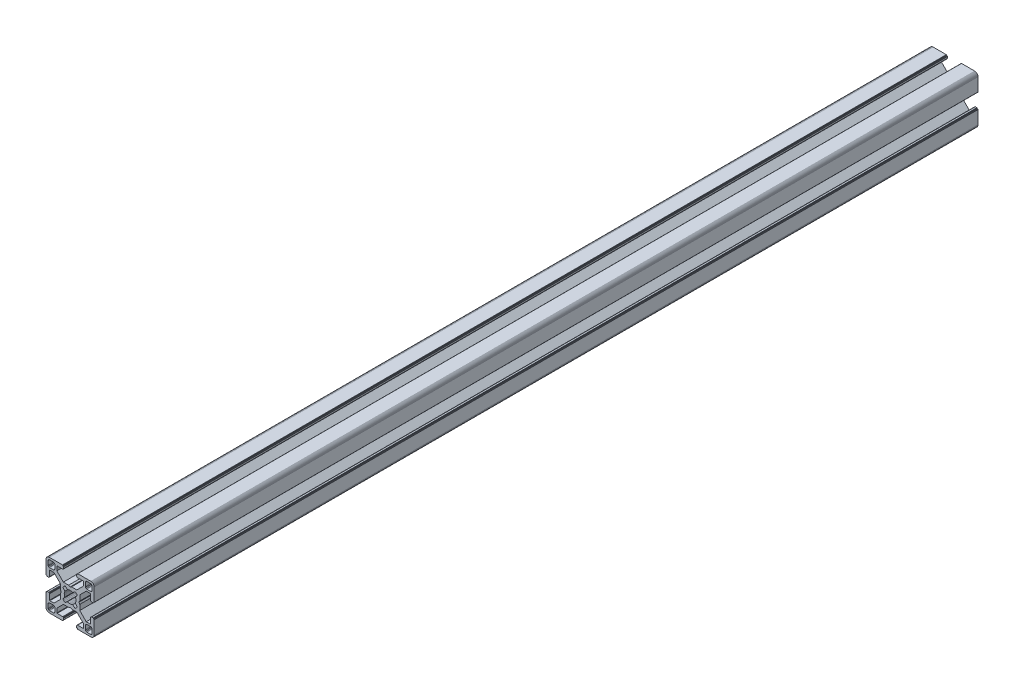
from build123d import *

# Parameters (mm, degrees)
BOSS_EXTRUDE1_DEPTH = 550


with BuildPart() as part:
    # Sketch1 → Boss-Extrude1 (new body)
    with BuildSketch(Plane.XY):
        Polygon((28.34729664, 29.969613999), (28.000000864, 29.999999329), (19.750000909, 29.999999329), (19.715268165, 29.996961355), (19.681595266, 29.987938702), (19.649999216, 29.973205179), (19.621443003, 29.953207821), (19.596790895, 29.928557575), (19.576793537, 29.899999499), (19.562061876, 29.868405312), (19.55303736, 29.834728688), (19.549999386, 29.799999669), (19.549999386, 29.699999839), (19.546961412, 29.665268958), (19.537936896, 29.631596059), (19.523203373, 29.599998146), (19.503207877, 29.571441934), (19.478557631, 29.546789825), (19.449999556, 29.526794329), (19.418403506, 29.512060806), (19.384728745, 29.503038153), (19.349999726, 29.500000179), (19.249999896, 29.500000179), (19.215267517, 29.496958527), (19.181592755, 29.487935874), (19.149996706, 29.47320235), (19.12143863, 29.453206855), (19.096788384, 29.428554746), (19.076791026, 29.399996671), (19.062057503, 29.368402484), (19.05303485, 29.334725859), (19.049996876, 29.299998703), (19.049996876, 28.39999837), (19.059110798, 28.29580945), (19.08618062, 28.194785165), (19.13038119, 28.099997016), (19.190369539, 28.014324653), (19.264324002, 27.94037019), (19.349996366, 27.88038184), (19.444784515, 27.836181271), (19.545806937, 27.809111449), (19.650010894, 27.799984574), (23.050010706, 27.799984574), (23.084741588, 27.7969466), (23.118414487, 27.787923946), (23.150012399, 27.773190423), (23.178568612, 27.753193065), (23.203220721, 27.728542819), (23.223218079, 27.699984744), (23.237949739, 27.668386831), (23.246974255, 27.634713932), (23.25001142, 27.59998608), (23.25001142, 25.049987618), (19.204474482, 20.999982084), (15.900007876, 20.999982084), (15.000008474, 20.48483404), (14.10000814, 20.999982084), (10.795543398, 20.999982084), (7.997342887, 23.801274731), (6.750011387, 25.049984589), (6.750011387, 27.599983051), (6.753049362, 27.634713932), (6.762072946, 27.668386831), (6.776805538, 27.699984744), (6.796801965, 27.728542819), (6.821454073, 27.753193065), (6.850011218, 27.773190423), (6.881607267, 27.787923946), (6.915282029, 27.7969466), (6.950011048, 27.799984574), (10.350011791, 27.799984574), (10.45420071, 27.809098497), (10.555223133, 27.836168318), (10.650011282, 27.880368888), (10.735683645, 27.940357238), (10.809638108, 28.014311701), (10.869626458, 28.099984064), (10.913827027, 28.194772213), (10.940895918, 28.295796498), (10.950010772, 28.399985417), (10.950010772, 29.299985751), (10.946974575, 29.334739239), (10.93795065, 29.368415522), (10.923215933, 29.400009153), (10.903218427, 29.428566473), (10.878566319, 29.45321765), (10.849999264, 29.473204166), (10.818403214, 29.487937689), (10.784728453, 29.496960342), (10.749999434, 29.500000179), (10.649999604, 29.500000179), (10.615270585, 29.503038153), (10.581595823, 29.512060806), (10.549999774, 29.526794329), (10.521441698, 29.546789825), (10.496791452, 29.571441934), (10.476795025, 29.599998146), (10.462061502, 29.631596059), (10.453037918, 29.665268958), (10.449999943, 29.699999839), (10.449999943, 29.799999669), (10.446961969, 29.834728688), (10.437938385, 29.868405312), (10.423205793, 29.899999499), (10.403208435, 29.928557575), (10.378557257, 29.953207821), (10.350000113, 29.973205179), (10.318404064, 29.987938702), (10.284729302, 29.996961355), (10.250000283, 29.999999329), (1.999999397, 29.999999329), (1.652702689, 29.969613999), (1.315958682, 29.879383743), (0.999999233, 29.732050374), (0.714424066, 29.532089829), (0.467910431, 29.285576195), (0.267948955, 28.999999166), (0.120614655, 28.684040532), (0.030384399, 28.34729664), (0, 28.000000864), (0, 19.750000909), (0.003037974, 19.715268165), (0.012061559, 19.681595266), (0.026795082, 19.649999216), (0.046790577, 19.621441141), (0.071442686, 19.596789032), (0.09999983, 19.576793537), (0.13159588, 19.562060013), (0.165270641, 19.55303736), (0.19999966, 19.549999386), (0.299999461, 19.549999386), (0.334728509, 19.546959549), (0.368403242, 19.537936896), (0.399999321, 19.523203373), (0.428556465, 19.503207877), (0.453208573, 19.478555769), (0.473204069, 19.449997693), (0.487937592, 19.418403506), (0.496961176, 19.384728745), (0.499999151, 19.349999726), (0.499999151, 19.249998033), (0.503038056, 19.215269014), (0.512060709, 19.181594253), (0.526794232, 19.150000066), (0.546790194, 19.121441524), (0.571441837, 19.096789882), (0.60000029, 19.076794925), (0.631595686, 19.062061999), (0.665270619, 19.053039982), (0.700000626, 19.050000801), (1.60000096, 19.050000801), (1.704189879, 19.059116587), (1.805213233, 19.086186409), (1.90000045, 19.130385115), (1.985673745, 19.190375328), (2.059627277, 19.264327928), (2.119616325, 19.350002154), (2.163816196, 19.444788441), (2.190886018, 19.545812726), (2.200000872, 19.650001645), (2.200000872, 23.050001457), (2.203039777, 23.084732338), (2.212062431, 23.118405237), (2.226795954, 23.15000315), (2.246792381, 23.178559362), (2.271443558, 23.203211471), (2.300000702, 23.223206967), (2.331596752, 23.23794049), (2.365271513, 23.246965006), (2.400001464, 23.250001117), (4.950000857, 23.250001117), (7.997332093, 20.202670812), (8.995535423, 19.204467788), (8.995535423, 15.900001182), (9.515148227, 15.00000178), (8.995535423, 14.100002378), (8.995535423, 10.795536704), (4.950000857, 6.750002138), (2.400001464, 6.750002138), (2.365271513, 6.753040112), (2.331596752, 6.762063697), (2.300000702, 6.77679722), (2.271443558, 6.796793647), (2.246792381, 6.821444824), (2.226795954, 6.850001968), (2.212062431, 6.881598018), (2.203039777, 6.915272779), (2.200000872, 6.950002729), (2.200000872, 10.350002542), (2.190896812, 10.454174265), (2.16382699, 10.555197618), (2.119627119, 10.649984836), (2.059638071, 10.735658131), (1.985684539, 10.809611663), (1.900011244, 10.869600944), (1.805224027, 10.913800582), (1.704200673, 10.940870404), (1.600011754, 10.949986189), (0.70001142, 10.949986189), (0.665281355, 10.946948596), (0.631606253, 10.937926283), (0.600010578, 10.923193954), (0.571451747, 10.903199537), (0.546799638, 10.87854836), (0.526794232, 10.850000195), (0.512060709, 10.818404146), (0.503038056, 10.784730315), (0.499999151, 10.750000365), (0.499999151, 10.650000535), (0.496961176, 10.615270585), (0.487937592, 10.581596754), (0.473204069, 10.550000705), (0.453208573, 10.521443561), (0.428556465, 10.496791452), (0.399999321, 10.476795956), (0.368403242, 10.462062433), (0.334728509, 10.453038849), (0.299999461, 10.449999943), (0.19999966, 10.449999943), (0.165270641, 10.446961969), (0.13159588, 10.437939316), (0.09999983, 10.423205793), (0.071442686, 10.403209366), (0.046790577, 10.378558189), (0.026795082, 10.350000113), (0.012061559, 10.318404064), (0.003037974, 10.284729302), (0, 10.250000283), (0, 1.999999397), (0.030384399, 1.652702689), (0.120614655, 1.315958682), (0.267948955, 0.999999233), (0.467910431, 0.714424066), (0.714424066, 0.467910431), (0.999999233, 0.267948955), (1.315958682, 0.120614655), (1.652702689, 0.030384399), (1.999999397, 0), (10.250000283, 0), (10.284729302, 0.003037974), (10.318404064, 0.012061559), (10.350000113, 0.026795082), (10.378557257, 0.046790577), (10.403208435, 0.071442686), (10.423205793, 0.09999983), (10.437938385, 0.13159588), (10.446961969, 0.165270641), (10.449999943, 0.19999966), (10.449999943, 0.300000422), (10.453037918, 0.334729441), (10.462061502, 0.368404202), (10.476795025, 0.400000252), (10.496791452, 0.428557396), (10.521441698, 0.453208573), (10.549999774, 0.473205), (10.581595823, 0.487938523), (10.615270585, 0.496961176), (10.649999604, 0.500000082), (10.749999434, 0.500000082), (10.784728453, 0.503038056), (10.818403214, 0.512060709), (10.849999264, 0.526794232), (10.878547894, 0.546800104), (10.903198606, 0.571451747), (10.923194493, 0.6000102), (10.93792742, 0.631606528), (10.946949437, 0.66528146), (10.950010772, 0.699984975), (10.950010772, 1.599985308), (10.940895918, 1.704174228), (10.913827027, 1.805197581), (10.869626458, 1.89998573), (10.809638108, 1.985658094), (10.735683645, 2.059612557), (10.650011282, 2.119600674), (10.555223133, 2.163801476), (10.45420071, 2.190870367), (10.350011791, 2.199985221), (6.950011048, 2.199985221), (6.915282029, 2.203024126), (6.881607267, 2.212046779), (6.850011218, 2.226780302), (6.821454073, 2.246776729), (6.796801965, 2.271427907), (6.776805538, 2.299985982), (6.762072946, 2.331582032), (6.753049362, 2.365256793), (6.750011387, 2.399985812), (6.750011387, 4.949985206), (9.787457566, 7.990785077), (10.795545277, 8.999985833), (14.100010019, 8.999985833), (15.000010353, 9.515133877), (15.900009756, 8.999985833), (19.204476361, 8.999985833), (20.21256413, 7.990786065), (23.25001142, 4.949988235), (23.25001142, 2.399988841), (23.246974255, 2.365256793), (23.237949739, 2.331582032), (23.223218079, 2.299985982), (23.203220721, 2.271427907), (23.178568612, 2.246776729), (23.150012399, 2.226780302), (23.118414487, 2.212046779), (23.084741588, 2.203024126), (23.050010706, 2.199985221), (19.650010894, 2.199985221), (19.545806937, 2.190883319), (19.444784515, 2.163814428), (19.349996366, 2.119613626), (19.264324002, 2.059625509), (19.190369539, 1.985671046), (19.13038119, 1.899998682), (19.08618062, 1.805210533), (19.059110798, 1.70418718), (19.049996876, 1.599998261), (19.049996876, 0.699997927), (19.053035506, 0.665268966), (19.062058795, 0.631594374), (19.076792915, 0.599998603), (19.096790813, 0.571440905), (19.121441524, 0.546790194), (19.149999978, 0.526794306), (19.181596306, 0.51206138), (19.215271238, 0.503039363), (19.249999896, 0.500000082), (19.349999726, 0.500000082), (19.384728745, 0.496961176), (19.418403506, 0.487938523), (19.449999556, 0.473205), (19.478557631, 0.453208573), (19.503207877, 0.428557396), (19.523203373, 0.400000252), (19.537936896, 0.368404202), (19.546961412, 0.334729441), (19.549999386, 0.300000422), (19.549999386, 0.19999966), (19.55303736, 0.165270641), (19.562061876, 0.13159588), (19.576793537, 0.09999983), (19.596789964, 0.071441755), (19.621442072, 0.046789646), (19.649998285, 0.02679415), (19.681594335, 0.012060627), (19.715267234, 0.003037043), (19.750000909, 0), (28.000000864, 0), (28.34729664, 0.030384399), (28.684040532, 0.120614655), (28.999999166, 0.267948955), (29.285576195, 0.467910431), (29.532089829, 0.714424066), (29.732050374, 0.999999233), (29.879383743, 1.315958682), (29.969613999, 1.652702689), (29.999999329, 1.999999397), (29.999999329, 10.250000283), (29.996974806, 10.284715361), (29.987951516, 10.318389952), (29.973217396, 10.349985723), (29.953219499, 10.378543421), (29.928568787, 10.403194133), (29.899999499, 10.423205793), (29.868405312, 10.437939316), (29.834728688, 10.446961969), (29.799999669, 10.449999943), (29.699999839, 10.449999943), (29.664909937, 10.453400043), (29.631233313, 10.462423628), (29.599637263, 10.477157151), (29.57108105, 10.497152646), (29.546427079, 10.521804755), (29.526433446, 10.550361899), (29.511699923, 10.581957949), (29.502675407, 10.615631779), (29.499637433, 10.650361729), (29.499637433, 10.750361559), (29.49697202, 10.784715548), (29.487949367, 10.818389378), (29.473215844, 10.849985428), (29.453220348, 10.878542572), (29.428568239, 10.90319468), (29.400010164, 10.923190176), (29.368415977, 10.937923699), (29.334741215, 10.946947284), (29.300012197, 10.949986189), (28.400011863, 10.949986189), (28.29581215, 10.9408876), (28.194787865, 10.913817778), (28.099999716, 10.86961814), (28.014327352, 10.809628859), (27.940374752, 10.735675327), (27.880384539, 10.650002032), (27.836185833, 10.555214814), (27.809114148, 10.454191461), (27.800000225, 10.350002542), (27.800000225, 6.950002729), (27.796962251, 6.915272779), (27.787939598, 6.881598018), (27.773206075, 6.850001968), (27.753208716, 6.821444824), (27.728558471, 6.796793647), (27.700000395, 6.77679722), (27.668404345, 6.762063697), (27.634729584, 6.753040112), (27.599998702, 6.750002138), (25.05000024, 6.750002138), (23.809199132, 7.99080223), (21.004464477, 10.795534588), (21.004464477, 14.100000262), (20.484851673, 14.999999665), (21.004464477, 15.899999067), (21.004464477, 19.204465672), (25.05000024, 23.250001117), (27.599998702, 23.250001117), (27.634729584, 23.246965006), (27.668404345, 23.23794049), (27.700000395, 23.223206967), (27.728558471, 23.203211471), (27.753208716, 23.178559362), (27.773206075, 23.15000315), (27.787939598, 23.118405237), (27.796962251, 23.084732338), (27.800000225, 23.050001457), (27.800000225, 19.650001645), (27.809114148, 19.545812726), (27.836185833, 19.444788441), (27.880384539, 19.350002154), (27.940370508, 19.264323684), (28.014323108, 19.190371084), (28.099995472, 19.130380872), (28.194783621, 19.086182165), (28.295807906, 19.059112343), (28.400001069, 19.050000801), (29.300001402, 19.050000801), (29.334730421, 19.053040638), (29.368405183, 19.062063291), (29.39999937, 19.076796814), (29.42819671, 19.097149726), (29.452848353, 19.1218023), (29.472843309, 19.150360754), (29.487576235, 19.181955219), (29.496598252, 19.215630151), (29.499637433, 19.250359227), (29.499637433, 19.35036092), (29.502675407, 19.385089939), (29.511699923, 19.4187647), (29.526433446, 19.450358887), (29.546427079, 19.478916963), (29.57108105, 19.503569071), (29.599637263, 19.523564567), (29.631233313, 19.53829809), (29.664909937, 19.547320743), (29.699999839, 19.549999386), (29.799999669, 19.549999386), (29.834728688, 19.55303736), (29.868405312, 19.562060013), (29.899999499, 19.576793537), (29.928557575, 19.596789032), (29.953207821, 19.621441141), (29.973205179, 19.649999216), (29.987938702, 19.681595266), (29.996961355, 19.715268165), (29.999999329, 19.750000909), (29.999999329, 28.000000864), (29.969613999, 28.34729664), (29.879383743, 28.684040532), (29.732050374, 28.999999166), (29.532089829, 29.285576195), (29.285576195, 29.532089829), (28.999999166, 29.732050374), (28.684040532, 29.879383743), align=None)
        Polygon((1.299998723, 25.499999523), (1.299998723, 27.699999511), (1.312309876, 27.856435627), (1.348942518, 28.009016067), (1.408992335, 28.153989464), (1.490981318, 28.287785128), (1.592892222, 28.407108039), (1.71221327, 28.50901708), (1.846008119, 28.591006994), (1.9909814, 28.651056811), (2.143563703, 28.687689453), (2.299998887, 28.699999675), (4.499998875, 28.699999675), (4.656434059, 28.687689453), (4.809016362, 28.651056811), (4.953989759, 28.591006994), (5.087784491, 28.50901708), (5.207106471, 28.407108039), (5.309016444, 28.287785128), (5.391005427, 28.153989464), (5.451056175, 28.009016067), (5.487687886, 27.856435627), (5.499999039, 27.699999511), (5.499999039, 25.499999523), (5.487687886, 25.34356527), (5.451056175, 25.190982968), (5.391005427, 25.04600957), (5.309016444, 24.912213907), (5.207106471, 24.792892858), (5.087784491, 24.690981954), (4.953989759, 24.60899204), (4.809016362, 24.548944086), (4.656434059, 24.512309581), (4.499998875, 24.499999359), (2.299998887, 24.499999359), (2.143563703, 24.512309581), (1.9909814, 24.548944086), (1.846008119, 24.60899204), (1.71221327, 24.690981954), (1.592892222, 24.792892858), (1.490981318, 24.912213907), (1.408992335, 25.04600957), (1.348942518, 25.190982968), (1.312309876, 25.34356527), align=None, mode=Mode.SUBTRACT)
        Polygon((25.34356527, 28.687689453), (25.499999523, 28.699999675), (27.699999511, 28.699999675), (27.856435627, 28.687689453), (28.009017929, 28.651056811), (28.153991327, 28.591006994), (28.28778699, 28.50901708), (28.407108039, 28.407108039), (28.50901708, 28.287785128), (28.591006994, 28.153989464), (28.651056811, 28.009016067), (28.687689453, 27.856435627), (28.700001538, 27.699999511), (28.700001538, 25.499999523), (28.687689453, 25.34356527), (28.651056811, 25.190982968), (28.591006994, 25.04600957), (28.50901708, 24.912213907), (28.407108039, 24.792892858), (28.28778699, 24.690981954), (28.153991327, 24.60899204), (28.009017929, 24.548944086), (27.856435627, 24.512309581), (27.699999511, 24.499999359), (25.499999523, 24.499999359), (25.34356527, 24.512309581), (25.190982968, 24.548944086), (25.04600957, 24.60899204), (24.912215769, 24.690981954), (24.792892858, 24.792892858), (24.690981954, 24.912213907), (24.608993903, 25.04600957), (24.548944086, 25.190982968), (24.512311444, 25.34356527), (24.500001222, 25.499999523), (24.500001222, 27.699999511), (24.512311444, 27.856435627), (24.548944086, 28.009016067), (24.608993903, 28.153989464), (24.690981954, 28.287785128), (24.792892858, 28.407108039), (24.912215769, 28.50901708), (25.04600957, 28.591006994), (25.190982968, 28.651056811), align=None, mode=Mode.SUBTRACT)
        Polygon((14.999999665, 18.649999052), (15.550030395, 18.608318642), (16.087498516, 18.484227359), (16.600128263, 18.280562013), (18.13592948, 19.518401474), (18.644984812, 19.11874488), (19.103571773, 18.662061542), (19.505336881, 18.154669553), (18.280562013, 16.600130126), (18.484227359, 16.087498516), (18.608318642, 15.550030395), (18.649999052, 14.999999665), (18.608318642, 14.449968934), (18.484227359, 13.912500814), (18.280562013, 13.399870135), (19.505336881, 11.845329776), (19.103571773, 11.337937787), (18.644984812, 10.881252587), (18.13592948, 10.481598787), (16.600128263, 11.719437316), (16.087498516, 11.515771039), (15.550030395, 11.391680688), (14.999999665, 11.349999346), (14.449968934, 11.391680688), (13.912500814, 11.515771039), (13.399870135, 11.719437316), (11.864069849, 10.481598787), (11.355013587, 10.881252587), (10.896427557, 11.337937787), (10.494662449, 11.845329776), (11.719438247, 13.399870135), (11.515771039, 13.912500814), (11.391680688, 14.449968934), (11.349999346, 14.999999665), (11.391680688, 15.550030395), (11.515771039, 16.087498516), (11.719438247, 16.600130126), (10.494662449, 18.154669553), (10.896427557, 18.662061542), (11.355013587, 19.11874488), (11.864069849, 19.518401474), (13.399870135, 18.280562013), (13.912500814, 18.484227359), (14.449968934, 18.608318642), align=None, mode=Mode.SUBTRACT)
        Polygon((4.499998875, 1.299999771), (2.299998887, 1.299999771), (2.143563703, 1.312310807), (1.9909814, 1.348942518), (1.846008119, 1.408992335), (1.71221327, 1.490982249), (1.592892222, 1.592892222), (1.490981318, 1.712214202), (1.408992335, 1.846008934), (1.348942518, 1.990982331), (1.312309876, 2.143564634), (1.299998723, 2.299998887), (1.299998723, 4.499999806), (1.312309876, 4.656434059), (1.348942518, 4.809017293), (1.408992335, 4.95399069), (1.490981318, 5.087785423), (1.592892222, 5.207106471), (1.71221327, 5.309017375), (1.846008119, 5.391006358), (1.9909814, 5.451056175), (2.143563703, 5.487688817), (2.299998887, 5.49999997), (4.499998875, 5.49999997), (4.656434059, 5.487688817), (4.809016362, 5.451056175), (4.953989759, 5.391006358), (5.087784491, 5.309017375), (5.207106471, 5.207106471), (5.309016444, 5.087785423), (5.391005427, 4.95399069), (5.451056175, 4.809017293), (5.487687886, 4.656434059), (5.499999039, 4.499999806), (5.499999039, 2.299998887), (5.487687886, 2.143564634), (5.451056175, 1.990982331), (5.391005427, 1.846008934), (5.309016444, 1.712214202), (5.207106471, 1.592892222), (5.087784491, 1.490982249), (4.953989759, 1.408992335), (4.809016362, 1.348942518), (4.656434059, 1.312310807), align=None, mode=Mode.SUBTRACT)
        Polygon((27.699999511, 1.299999771), (25.499999523, 1.299999771), (25.34356527, 1.312310807), (25.190982968, 1.348942518), (25.04600957, 1.408992335), (24.912215769, 1.490982249), (24.792892858, 1.592892222), (24.690981954, 1.712214202), (24.608993903, 1.846008934), (24.548944086, 1.990982331), (24.512311444, 2.143564634), (24.500001222, 2.299998887), (24.500001222, 4.499999806), (24.512311444, 4.656434059), (24.548944086, 4.809017293), (24.608993903, 4.95399069), (24.690981954, 5.087785423), (24.792892858, 5.207106471), (24.912215769, 5.309017375), (25.04600957, 5.391006358), (25.190982968, 5.451056175), (25.34356527, 5.487688817), (25.499999523, 5.49999997), (27.699999511, 5.49999997), (27.856435627, 5.487688817), (28.009017929, 5.451056175), (28.153991327, 5.391006358), (28.28778699, 5.309017375), (28.407108039, 5.207106471), (28.50901708, 5.087785423), (28.591006994, 4.95399069), (28.651056811, 4.809017293), (28.687689453, 4.656434059), (28.700001538, 4.499999806), (28.700001538, 2.299998887), (28.687689453, 2.143564634), (28.651056811, 1.990982331), (28.591006994, 1.846008934), (28.50901708, 1.712214202), (28.407108039, 1.592892222), (28.28778699, 1.490982249), (28.153991327, 1.408992335), (28.009017929, 1.348942518), (27.856435627, 1.312310807), align=None, mode=Mode.SUBTRACT)
    extrude(amount=-BOSS_EXTRUDE1_DEPTH)


solid = part.part
